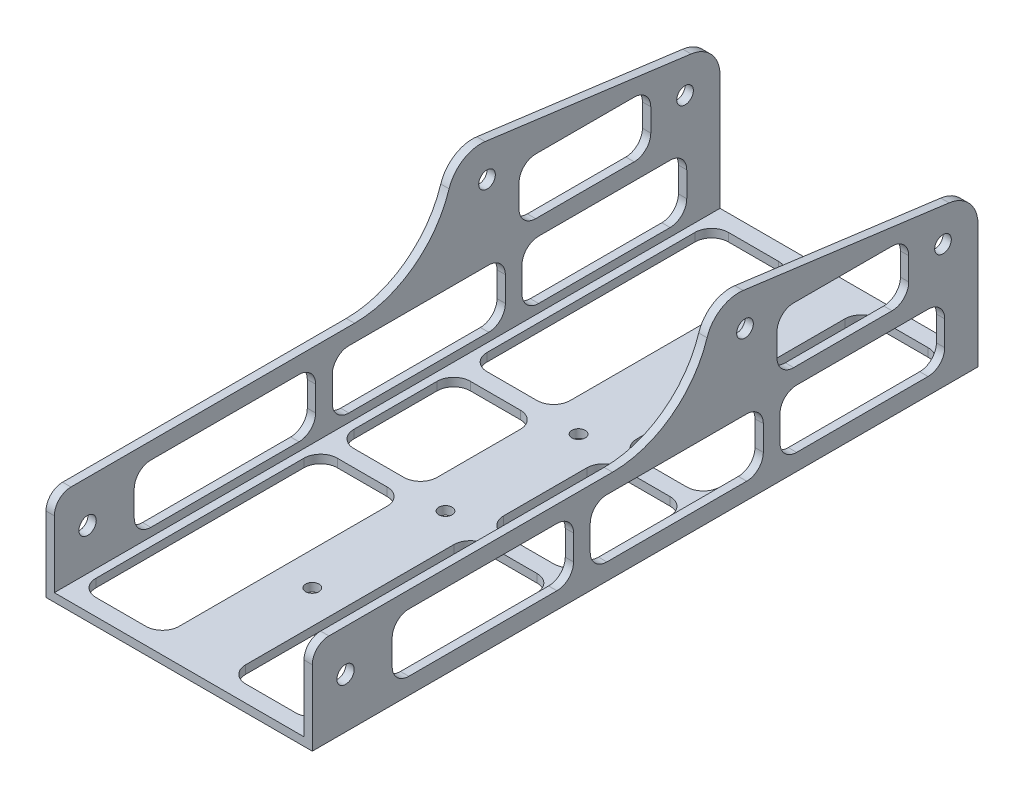
from build123d import *

# Parameters (mm, degrees)
BOSS_EXTRUDE1_DEPTH = 254
SKETCH2_R           = 3.302
SKETCH2_R_2         = 3.175
CUT_EXTRUDE1_DEPTH  = 203.2
SKETCH3_R           = 2.54
CUT_EXTRUDE2_DEPTH  = 9.525
CUT_EXTRUDE3_DEPTH  = 102.6
SKETCH5_R           = 3.175
CUT_EXTRUDE4_DEPTH  = 102.6
CUT_EXTRUDE6_DEPTH  = 102.6
FILLET1_R           = 12.7
FILLET2_R           = 6.35
CUT_EXTRUDE7_DEPTH  = 102.6
CUT_EXTRUDE8_DEPTH  = 116.332


with BuildPart() as part:
    # Sketch1 → Boss-Extrude1 (new body)
    with BuildSketch(Plane.XY):
        Polygon((0, 0), (0, 73.025), (3.175, 73.025), (3.175, 3.175), (98.425, 3.175), (98.425, 73.025), (101.6, 73.025), (101.6, 0), align=None)
    extrude(amount=BOSS_EXTRUDE1_DEPTH)

    # Sketch2 → Cut-Extrude1 (cut)
    with BuildSketch(Plane(origin=(101.6, 0, 0), x_dir=(0, 0, -1), z_dir=(1, 0, 0))):
        with Locations((-241.3, 19.05)):
            Circle(SKETCH2_R)
        with Locations((-88.9, 57.15)):
            Circle(SKETCH2_R_2)
    extrude(amount=-CUT_EXTRUDE1_DEPTH, mode=Mode.SUBTRACT)

    # Sketch3 → Cut-Extrude2 (cut)
    with BuildSketch(Plane(origin=(0, 3.175, 0), x_dir=(1, 0, 0), z_dir=(0, 1, 0))):
        with Locations((50.8, -50.8)):
            Circle(SKETCH3_R)
        with Locations((50.8, -101.6)):
            Circle(SKETCH3_R)
        with Locations((50.8, -152.4)):
            Circle(SKETCH3_R)
        with Locations((50.8, -203.2)):
            Circle(SKETCH3_R)
    extrude(amount=-CUT_EXTRUDE2_DEPTH, mode=Mode.SUBTRACT)

    # Sketch4 → Cut-Extrude3 (cut, through all)
    with BuildSketch(Plane(origin=(101.6, 0, 0), x_dir=(0, 0, -1), z_dir=(1, 0, 0))):
        with BuildLine():
            Line((-254, 73.025), (-101.6, 73.025))
            Line((-101.6, 73.025), (-101.6, 72.771))
            ThreePointArc((-101.6, 72.771), (-112.684836759, 46.009836759), (-139.446, 34.925))
            Line((-139.446, 34.925), (-254, 34.925))
            Line((-254, 34.925), (-254, 73.025))
        make_face()
    extrude(amount=-CUT_EXTRUDE3_DEPTH, mode=Mode.SUBTRACT)

    # Sketch5 → Cut-Extrude4 (cut, through all)
    with BuildSketch(Plane.ZY):
        with Locations((13.351901563, 47.203904153)):
            Circle(SKETCH5_R)
    extrude(amount=-CUT_EXTRUDE4_DEPTH, mode=Mode.SUBTRACT)

    # Sketch6 → Cut-Extrude6 (cut, through all)
    with BuildSketch(Plane.ZY):
        with BuildLine():
            ThreePointArc((101.6, 72.771), (101.604272359, 72.202347935), (101.617088473, 71.633824259))
            Line((101.617088473, 71.633824259), (117.259257027, 73.693154817))
            Line((117.259257027, 73.693154817), (117.259257027, 83.648914128))
            Line((117.259257027, 83.648914128), (-7.022067506, 78.935998732))
            Line((-7.022067506, 78.935998732), (-12.481674063, 56.612437199))
            Line((-12.481674063, 56.612437199), (0, 58.255680764))
            Line((0, 58.255680764), (0, 73.025))
            Line((0, 73.025), (101.6, 73.025))
            Line((101.6, 73.025), (101.6, 72.771))
        make_face()
        with BuildLine():
            Line((0, 58.255680764), (11.694218922, 59.795253892))
            Line((11.694218922, 59.795253892), (101.617088473, 71.633824259))
            ThreePointArc((101.617088473, 71.633824259), (101.604272359, 72.202347935), (101.6, 72.771))
            Line((101.6, 72.771), (101.6, 73.025))
            Line((101.6, 73.025), (0, 73.025))
            Line((0, 73.025), (0, 58.255680764))
        make_face()
    extrude(amount=-CUT_EXTRUDE6_DEPTH, mode=Mode.SUBTRACT)

    # Fillet1
    fillet1_edges = [part.edges().sort_by_distance(p)[0] for p in [
        (100.0125, 71.633824259, 101.617088473),
        (1.5875, 71.633824259, 101.617088473),
        (1.5875, 58.255680764, 0),
        (100.0125, 58.255680764, 0),
    ]]
    fillet(fillet1_edges, radius=FILLET1_R)

    # Fillet2
    fillet2_edges = [part.edges().sort_by_distance(p)[0] for p in [
        (100.0125, 34.925, 254),
        (1.5875, 34.925, 254),
    ]]
    fillet(fillet2_edges, radius=FILLET2_R)

    # Sketch7 → Cut-Extrude7 (cut, through all)
    with BuildSketch(Plane.ZY):
        with BuildLine():
            Line((26.426168463, 49.938693078), (26.426168463, 41.275))
            ThreePointArc((26.426168463, 41.275), (28.286040403, 36.784871939), (32.776168463, 34.925))
            Line((32.776168463, 34.925), (70.34221886, 34.925))
            ThreePointArc((70.34221886, 34.925), (74.832346921, 36.784871939), (76.69221886, 41.275))
            Line((76.69221886, 41.275), (76.69221886, 49.938693078))
            ThreePointArc((76.69221886, 49.938693078), (74.832346921, 54.428821139), (70.34221886, 56.288693078))
            Line((70.34221886, 56.288693078), (32.776168463, 56.288693078))
            ThreePointArc((32.776168463, 56.288693078), (28.286040403, 54.428821139), (26.426168463, 49.938693078))
        make_face()
        with BuildLine():
            Line((69.215, 28.575), (19.05, 28.575))
            ThreePointArc((19.05, 28.575), (14.559871939, 26.715128061), (12.7, 22.225))
            Line((12.7, 22.225), (12.7, 12.7))
            ThreePointArc((12.7, 12.7), (14.559871939, 8.209871939), (19.05, 6.35))
            Line((19.05, 6.35), (69.215, 6.35))
            ThreePointArc((69.215, 6.35), (73.705128061, 8.209871939), (75.565, 12.7))
            Line((75.565, 12.7), (75.565, 22.225))
            ThreePointArc((75.565, 22.225), (73.705128061, 26.715128061), (69.215, 28.575))
        make_face()
        with BuildLine():
            Line((81.915, 22.225), (81.915, 12.7))
            ThreePointArc((81.915, 12.7), (83.774871939, 8.209871939), (88.265, 6.35))
            Line((88.265, 6.35), (141.605, 6.35))
            ThreePointArc((141.605, 6.35), (146.095128061, 8.209871939), (147.955, 12.7))
            Line((147.955, 12.7), (147.955, 22.225))
            ThreePointArc((147.955, 22.225), (146.095128061, 26.715128061), (141.605, 28.575))
            Line((141.605, 28.575), (88.265, 28.575))
            ThreePointArc((88.265, 28.575), (83.774871939, 26.715128061), (81.915, 22.225))
        make_face()
        with BuildLine():
            Line((154.305, 22.225), (154.305, 12.7))
            ThreePointArc((154.305, 12.7), (156.164871939, 8.209871939), (160.655, 6.35))
            Line((160.655, 6.35), (217.17, 6.35))
            ThreePointArc((217.17, 6.35), (221.660128061, 8.209871939), (223.52, 12.7))
            Line((223.52, 12.7), (223.52, 22.225))
            ThreePointArc((223.52, 22.225), (221.660128061, 26.715128061), (217.17, 28.575))
            Line((217.17, 28.575), (160.655, 28.575))
            ThreePointArc((160.655, 28.575), (156.164871939, 26.715128061), (154.305, 22.225))
        make_face()
    extrude(amount=-CUT_EXTRUDE7_DEPTH, mode=Mode.SUBTRACT)

    # Sketch8 → Cut-Extrude8 (cut)
    with BuildSketch(Plane.XZ):
        with BuildLine():
            Line((31.75, 247.65), (12.7, 247.65))
            ThreePointArc((12.7, 247.65), (8.209871939, 245.790128061), (6.35, 241.3))
            Line((6.35, 241.3), (6.35, 212.725))
            ThreePointArc((6.35, 212.725), (8.209871939, 208.234871939), (12.7, 206.375))
            Line((12.7, 206.375), (31.75, 206.375))
            ThreePointArc((31.75, 206.375), (36.240128061, 208.234871939), (38.1, 212.725))
            Line((38.1, 212.725), (38.1, 241.3))
            ThreePointArc((38.1, 241.3), (36.240128061, 245.790128061), (31.75, 247.65))
        make_face()
        with BuildLine():
            ThreePointArc((88.9, 206.375), (93.390128061, 208.234871939), (95.25, 212.725))
            Line((95.25, 212.725), (95.25, 241.3))
            ThreePointArc((95.25, 241.3), (93.390128061, 245.790128061), (88.9, 247.65))
            Line((88.9, 247.65), (69.85, 247.65))
            ThreePointArc((69.85, 247.65), (65.359871939, 245.790128061), (63.5, 241.3))
            Line((63.5, 241.3), (63.5, 212.725))
            ThreePointArc((63.5, 212.725), (65.359871939, 208.234871939), (69.85, 206.375))
            Line((69.85, 206.375), (88.9, 206.375))
        make_face()
        with BuildLine():
            Line((31.75, 200.025), (12.7, 200.025))
            ThreePointArc((12.7, 200.025), (8.209871939, 198.165128061), (6.35, 193.675))
            Line((6.35, 193.675), (6.35, 161.925))
            ThreePointArc((6.35, 161.925), (8.209871939, 157.434871939), (12.7, 155.575))
            Line((12.7, 155.575), (31.75, 155.575))
            ThreePointArc((31.75, 155.575), (36.240128061, 157.434871939), (38.1, 161.925))
            Line((38.1, 161.925), (38.1, 193.675))
            ThreePointArc((38.1, 193.675), (36.240128061, 198.165128061), (31.75, 200.025))
        make_face()
        with BuildLine():
            ThreePointArc((88.9, 155.575), (93.390128061, 157.434871939), (95.25, 161.925))
            Line((95.25, 161.925), (95.25, 193.675))
            ThreePointArc((95.25, 193.675), (93.390128061, 198.165128061), (88.9, 200.025))
            Line((88.9, 200.025), (69.85, 200.025))
            ThreePointArc((69.85, 200.025), (65.359871939, 198.165128061), (63.5, 193.675))
            Line((63.5, 193.675), (63.5, 161.925))
            ThreePointArc((63.5, 161.925), (65.359871939, 157.434871939), (69.85, 155.575))
            Line((69.85, 155.575), (88.9, 155.575))
        make_face()
        with BuildLine():
            Line((31.75, 149.225), (12.7, 149.225))
            ThreePointArc((12.7, 149.225), (8.209871939, 147.365128061), (6.35, 142.875))
            Line((6.35, 142.875), (6.35, 111.125))
            ThreePointArc((6.35, 111.125), (8.209871939, 106.634871939), (12.7, 104.775))
            Line((12.7, 104.775), (31.75, 104.775))
            ThreePointArc((31.75, 104.775), (36.240128061, 106.634871939), (38.1, 111.125))
            Line((38.1, 111.125), (38.1, 142.875))
            ThreePointArc((38.1, 142.875), (36.240128061, 147.365128061), (31.75, 149.225))
        make_face()
        with BuildLine():
            ThreePointArc((88.9, 104.775), (93.390128061, 106.634871939), (95.25, 111.125))
            Line((95.25, 111.125), (95.25, 142.875))
            ThreePointArc((95.25, 142.875), (93.390128061, 147.365128061), (88.9, 149.225))
            Line((88.9, 149.225), (69.85, 149.225))
            ThreePointArc((69.85, 149.225), (65.359871939, 147.365128061), (63.5, 142.875))
            Line((63.5, 142.875), (63.5, 111.125))
            ThreePointArc((63.5, 111.125), (65.359871939, 106.634871939), (69.85, 104.775))
            Line((69.85, 104.775), (88.9, 104.775))
        make_face()
        with BuildLine():
            ThreePointArc((38.1, 60.325), (36.240128061, 55.834871939), (31.75, 53.975))
            Line((31.75, 53.975), (12.7, 53.975))
            ThreePointArc((12.7, 53.975), (8.209871939, 55.834871939), (6.35, 60.325))
            Line((6.35, 60.325), (6.35, 92.075))
            ThreePointArc((6.35, 92.075), (8.209871939, 96.565128061), (12.7, 98.425))
            Line((12.7, 98.425), (31.75, 98.425))
            ThreePointArc((31.75, 98.425), (36.240128061, 96.565128061), (38.1, 92.075))
            Line((38.1, 92.075), (38.1, 60.325))
        make_face()
        with BuildLine():
            Line((63.5, 92.075), (63.5, 60.325))
            ThreePointArc((63.5, 60.325), (65.359871939, 55.834871939), (69.85, 53.975))
            Line((69.85, 53.975), (88.9, 53.975))
            ThreePointArc((88.9, 53.975), (93.390128061, 55.834871939), (95.25, 60.325))
            Line((95.25, 60.325), (95.25, 92.075))
            ThreePointArc((95.25, 92.075), (93.390128061, 96.565128061), (88.9, 98.425))
            Line((88.9, 98.425), (69.85, 98.425))
            ThreePointArc((69.85, 98.425), (65.359871939, 96.565128061), (63.5, 92.075))
        make_face()
        with BuildLine():
            Line((31.75, 47.625), (12.7, 47.625))
            ThreePointArc((12.7, 47.625), (8.209871939, 45.765128061), (6.35, 41.275))
            Line((6.35, 41.275), (6.35, 12.7))
            ThreePointArc((6.35, 12.7), (8.209871939, 8.209871939), (12.7, 6.35))
            Line((12.7, 6.35), (31.75, 6.35))
            ThreePointArc((31.75, 6.35), (36.240128061, 8.209871939), (38.1, 12.7))
            Line((38.1, 12.7), (38.1, 41.275))
            ThreePointArc((38.1, 41.275), (36.240128061, 45.765128061), (31.75, 47.625))
        make_face()
        with BuildLine():
            ThreePointArc((69.85, 47.625), (65.359871939, 45.765128061), (63.5, 41.275))
            Line((63.5, 41.275), (63.5, 12.7))
            ThreePointArc((63.5, 12.7), (65.359871939, 8.209871939), (69.85, 6.35))
            Line((69.85, 6.35), (88.9, 6.35))
            ThreePointArc((88.9, 6.35), (93.390128061, 8.209871939), (95.25, 12.7))
            Line((95.25, 12.7), (95.25, 41.275))
            ThreePointArc((95.25, 41.275), (93.390128061, 45.765128061), (88.9, 47.625))
            Line((88.9, 47.625), (69.85, 47.625))
        make_face()
        with BuildLine():
            Line((38.1, 193.675), (38.1, 212.725))
            ThreePointArc((38.1, 212.725), (36.240128061, 208.234871939), (31.75, 206.375))
            Line((31.75, 206.375), (12.7, 206.375))
            ThreePointArc((12.7, 206.375), (8.209871939, 208.234871939), (6.35, 212.725))
            Line((6.35, 212.725), (6.35, 193.675))
            ThreePointArc((6.35, 193.675), (8.209871939, 198.165128061), (12.7, 200.025))
            Line((12.7, 200.025), (31.75, 200.025))
            ThreePointArc((31.75, 200.025), (36.240128061, 198.165128061), (38.1, 193.675))
        make_face()
        with BuildLine():
            Line((38.1, 41.275), (38.1, 60.325))
            ThreePointArc((38.1, 60.325), (36.240128061, 55.834871939), (31.75, 53.975))
            Line((31.75, 53.975), (12.7, 53.975))
            ThreePointArc((12.7, 53.975), (8.209871939, 55.834871939), (6.35, 60.325))
            Line((6.35, 60.325), (6.35, 41.275))
            ThreePointArc((6.35, 41.275), (8.209871939, 45.765128061), (12.7, 47.625))
            Line((12.7, 47.625), (31.75, 47.625))
            ThreePointArc((31.75, 47.625), (36.240128061, 45.765128061), (38.1, 41.275))
        make_face()
        with BuildLine():
            ThreePointArc((88.9, 200.025), (93.390128061, 198.165128061), (95.25, 193.675))
            Line((95.25, 193.675), (95.25, 212.725))
            ThreePointArc((95.25, 212.725), (93.390128061, 208.234871939), (88.9, 206.375))
            Line((88.9, 206.375), (69.85, 206.375))
            ThreePointArc((69.85, 206.375), (65.359871939, 208.234871939), (63.5, 212.725))
            Line((63.5, 212.725), (63.5, 203.2))
            Line((63.5, 203.2), (63.5, 193.675))
            ThreePointArc((63.5, 193.675), (65.359871939, 198.165128061), (69.85, 200.025))
            Line((69.85, 200.025), (88.9, 200.025))
        make_face()
        with BuildLine():
            Line((63.5, 60.325), (63.5, 50.8))
            Line((63.5, 50.8), (63.5, 41.275))
            ThreePointArc((63.5, 41.275), (65.359871939, 45.765128061), (69.85, 47.625))
            Line((69.85, 47.625), (88.9, 47.625))
            ThreePointArc((88.9, 47.625), (93.390128061, 45.765128061), (95.25, 41.275))
            Line((95.25, 41.275), (95.25, 60.325))
            ThreePointArc((95.25, 60.325), (93.390128061, 55.834871939), (88.9, 53.975))
            Line((88.9, 53.975), (69.85, 53.975))
            ThreePointArc((69.85, 53.975), (65.359871939, 55.834871939), (63.5, 60.325))
        make_face()
    extrude(amount=-CUT_EXTRUDE8_DEPTH, mode=Mode.SUBTRACT)


solid = part.part
